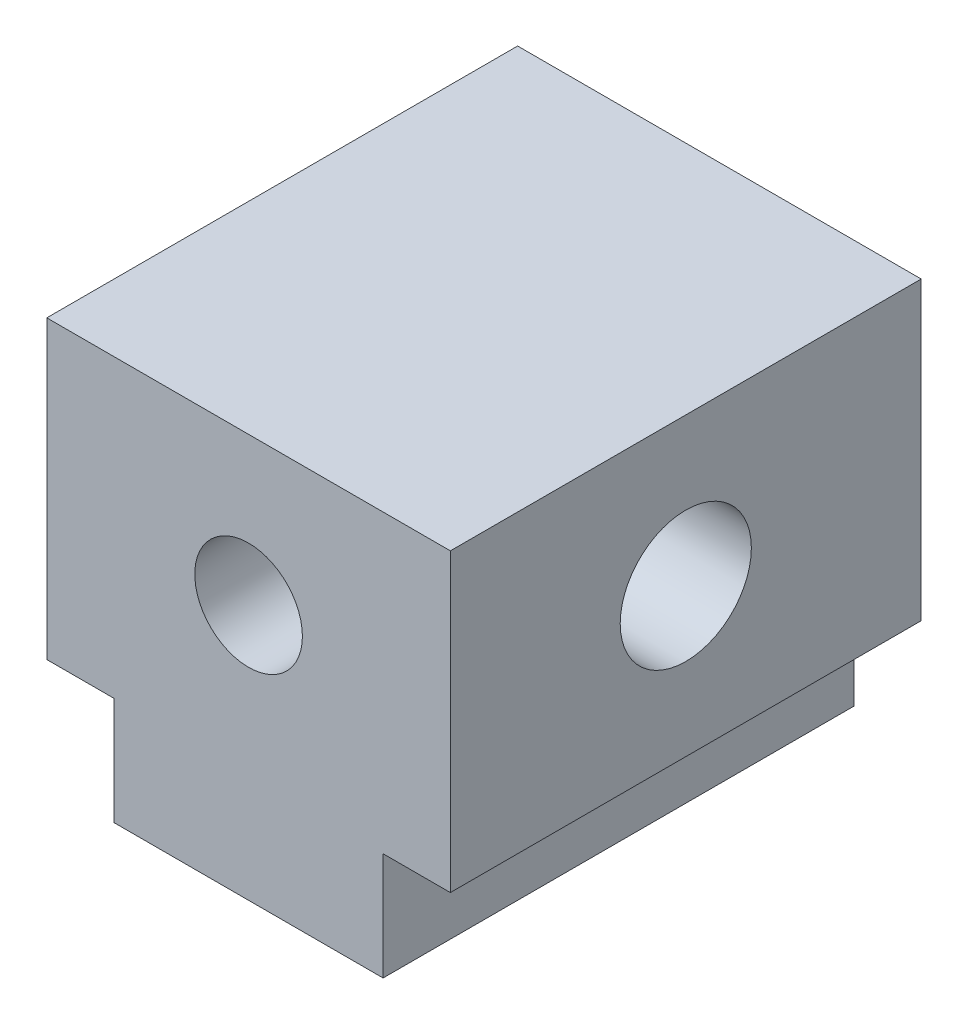
from build123d import *

# Parameters (mm, degrees)
SKETCH1_W           = 4
SKETCH1_H           = 7
BOSS_EXTRUDE1_DEPTH = 6
SKETCH2_W           = 1.5
SKETCH2_H           = 4.7
CUT_EXTRUDE1_DEPTH  = 1.5
CUT_EXTRUDE2_REACH  = 9
SKETCH3_R           = 0.8
SKETCH5_W           = 1
SKETCH5_H           = 4.4
BOSS_EXTRUDE2_DEPTH = 7
SKETCH4_R           = 0.975
CUT_EXTRUDE4_DEPTH  = 7


with BuildPart() as part:
    # Sketch1 → Boss-Extrude1 (new body)
    with BuildSketch(Plane(origin=(0, 0, 0), x_dir=(1, 0, 0), z_dir=(0, 1, 0))):
        Rectangle(SKETCH1_W, SKETCH1_H)
    extrude(amount=BOSS_EXTRUDE1_DEPTH)

    # Sketch2 → Cut-Extrude1 (cut)
    with BuildSketch(Plane.XZ):
        Rectangle(SKETCH2_W, SKETCH2_H)
    extrude(amount=-CUT_EXTRUDE1_DEPTH, mode=Mode.SUBTRACT)

    # Sketch3 → Cut-Extrude2 (cut, up to next)
    with BuildSketch(Plane.XY.offset(3.5), mode=Mode.PRIVATE) as cut_extrude2_sk1:
        with Locations((0, 3.8)):
            Circle(SKETCH3_R)
    cut_extrude2_tool1 = extrude(cut_extrude2_sk1.sketch, amount=-CUT_EXTRUDE2_REACH, mode=Mode.PRIVATE) & part.part
    add(cut_extrude2_tool1.solids().sort_by_distance((0, 3.8, 3.5))[0], mode=Mode.SUBTRACT)

    # Sketch5 → Boss-Extrude2 (add)
    with BuildSketch(Plane.XY.offset(3.5)):
        with Locations((2.5, 3.8)):
            Rectangle(SKETCH5_W, SKETCH5_H)
        with Locations((-2.5, 3.8)):
            Rectangle(SKETCH5_W, SKETCH5_H)
    extrude(amount=-BOSS_EXTRUDE2_DEPTH)

    # Sketch4 → Cut-Extrude4 (cut, through all)
    with BuildSketch(Plane.ZY.offset(3)):
        with Locations((0, 3.8)):
            Circle(SKETCH4_R)
    extrude(amount=-CUT_EXTRUDE4_DEPTH, mode=Mode.SUBTRACT)


solid = part.part
